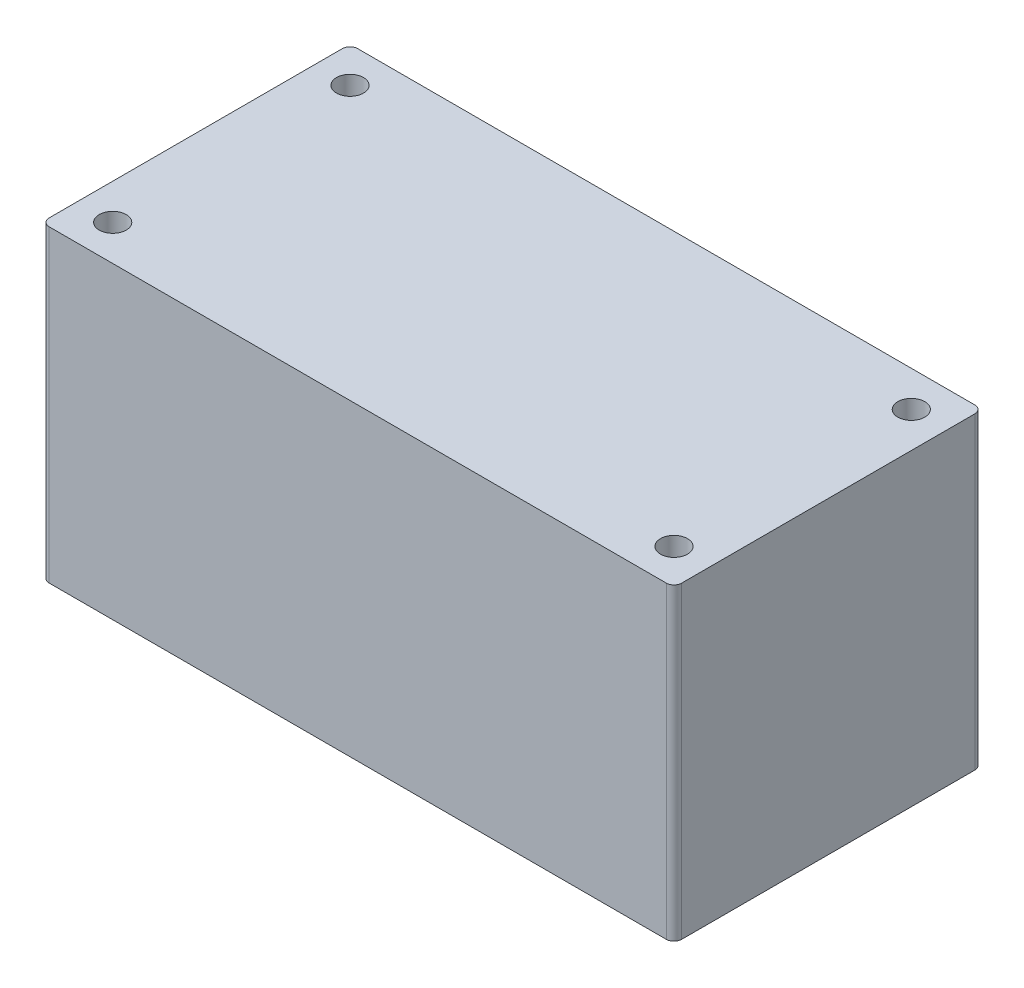
from build123d import *

# Parameters (mm, degrees)
SKETCH2_W           = 41
SKETCH2_H           = 20
BOSS_EXTRUDE1_DEPTH = 20
FILLET1_R           = 0.5
SKETCH3_R           = 0.875
CUT_EXTRUDE1_DEPTH  = 21


with BuildPart() as part:
    # Sketch2 → Boss-Extrude1 (new body)
    with BuildSketch(Plane(origin=(0, 0, 0), x_dir=(1, 0, 0), z_dir=(0, 1, 0))):
        Rectangle(SKETCH2_W, SKETCH2_H)
    extrude(amount=BOSS_EXTRUDE1_DEPTH)

    # Fillet1
    fillet1_edges = [part.edges().sort_by_distance(p)[0] for p in [
        (20.5, 10, 10),
        (-20.5, 10, 10),
        (-20.5, 10, -10),
        (20.5, 10, -10),
    ]]
    fillet(fillet1_edges, radius=FILLET1_R)

    # Sketch3 → Cut-Extrude1 (cut, through all)
    with BuildSketch(Plane(origin=(0, 20, 0), x_dir=(1, 0, 0), z_dir=(0, 1, 0))):
        with Locations((18.190909091, 7.690909091)):
            Circle(SKETCH3_R)
        with Locations((18.190909091, -7.690909091)):
            Circle(SKETCH3_R)
        with Locations((-18.190909091, 7.690909091)):
            Circle(SKETCH3_R)
        with Locations((-18.190909091, -7.690909091)):
            Circle(SKETCH3_R)
    extrude(amount=-CUT_EXTRUDE1_DEPTH, mode=Mode.SUBTRACT)


solid = part.part
